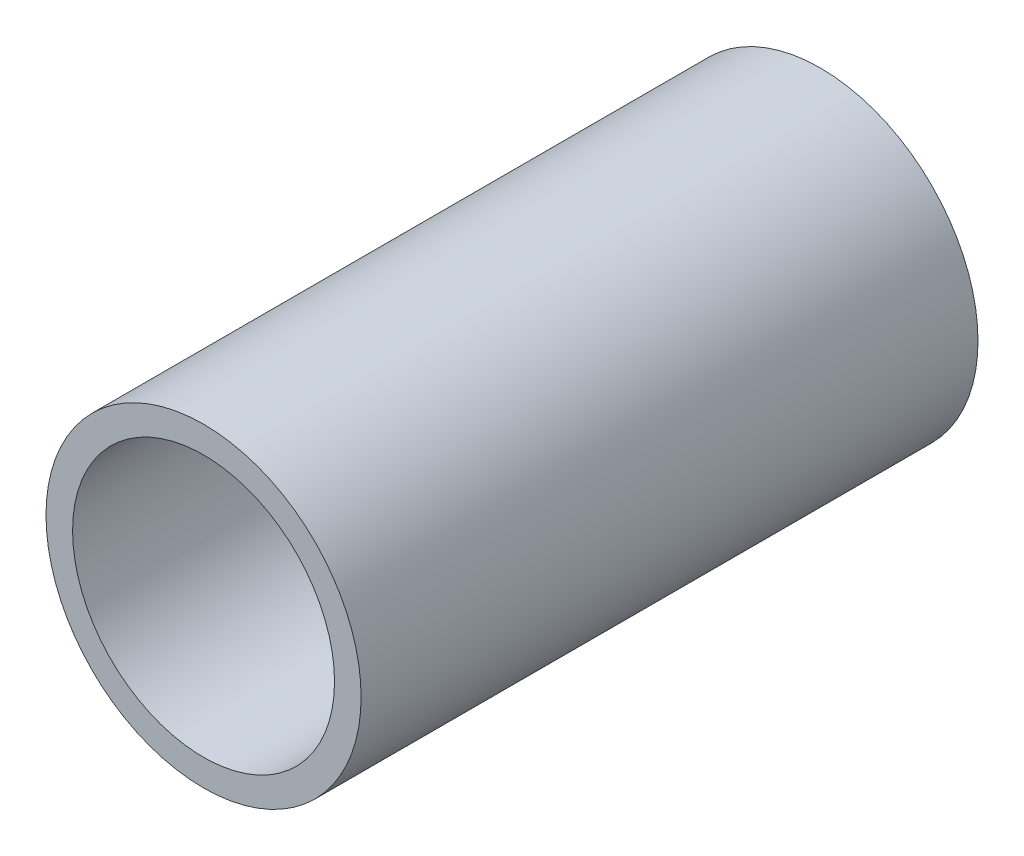
from build123d import *

# Parameters (mm, degrees)
SKETCH1_R           = 21.082
SKETCH1_R_2         = 17.526
EXTRUDE_THIN1_DEPTH = 41.275


with BuildPart() as part:
    # Sketch1 → Extrude-Thin1 (new body, symmetric)
    with BuildSketch(Plane.XY):
        Circle(SKETCH1_R)
        Circle(SKETCH1_R_2, mode=Mode.SUBTRACT)
    extrude(amount=EXTRUDE_THIN1_DEPTH, both=True)


solid = part.part
